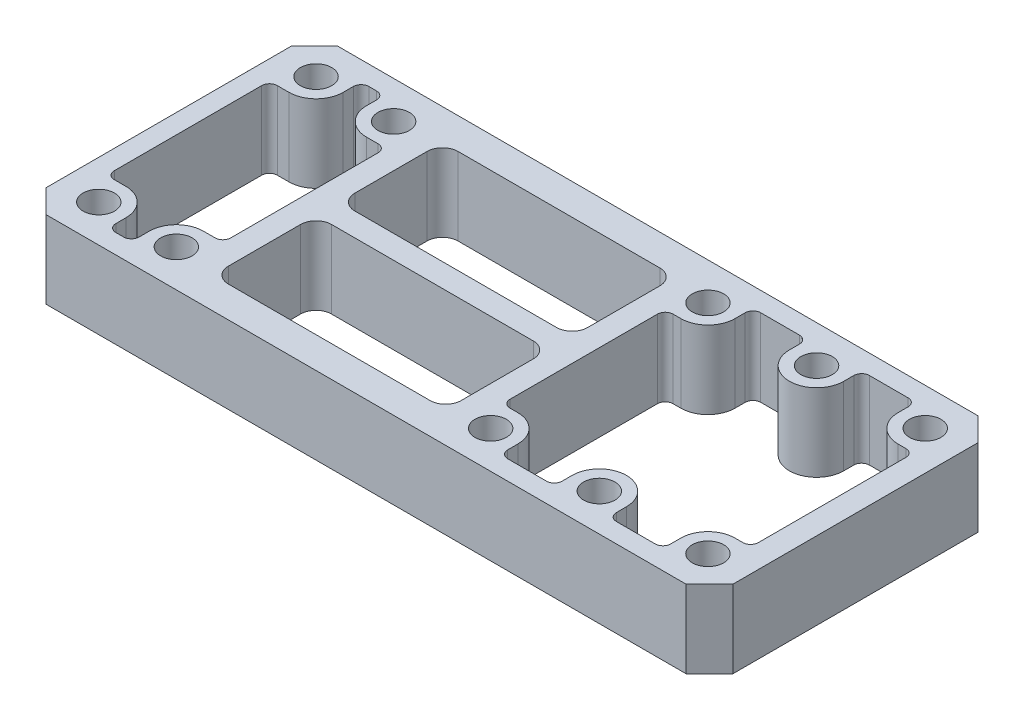
from build123d import *

# Parameters (mm, degrees)
SKETCH_1_W          = 88.5
SKETCH_1_H          = 37.6
SKETCH_1_R          = 2.025
EXTRUDE_1_DEPTH     = 10
CUT_EXTRUDE_1_DEPTH = 11
CUT_EXTRUDE_2_DEPTH = 11
SKETCH_4_W          = 30
SKETCH_4_H          = 29.6
CUT_EXTRUDE_3_DEPTH = 11
SKETCH_5_W          = 30
SKETCH_5_H          = 3
EXTRUDE_2_DEPTH     = 10
FILLET_1_R          = 2
CHAMFER_1_SIZE      = 3


with BuildPart() as part:
    # 草图1 → 凸台-拉伸1 (new body)
    with BuildSketch(Plane(origin=(0, 0, 0), x_dir=(1, 0, 0), z_dir=(0, 1, 0))):
        with Locations((34.25, 0)):
            Rectangle(SKETCH_1_W, SKETCH_1_H)
        with Locations((-5, 14)):
            Circle(SKETCH_1_R, mode=Mode.SUBTRACT)
        with Locations((5, 14)):
            Circle(SKETCH_1_R, mode=Mode.SUBTRACT)
        with Locations((5, -14)):
            Circle(SKETCH_1_R, mode=Mode.SUBTRACT)
        with Locations((-5, -14)):
            Circle(SKETCH_1_R, mode=Mode.SUBTRACT)
        with Locations((45.5, 14)):
            Circle(SKETCH_1_R, mode=Mode.SUBTRACT)
        with Locations((59.5, 14)):
            Circle(SKETCH_1_R, mode=Mode.SUBTRACT)
        with Locations((73.5, 14)):
            Circle(SKETCH_1_R, mode=Mode.SUBTRACT)
        with Locations((73.5, -14)):
            Circle(SKETCH_1_R, mode=Mode.SUBTRACT)
        with Locations((59.5, -14)):
            Circle(SKETCH_1_R, mode=Mode.SUBTRACT)
        with Locations((45.5, -14)):
            Circle(SKETCH_1_R, mode=Mode.SUBTRACT)
    extrude(amount=EXTRUDE_1_DEPTH)

    # 草图2 → 切除-拉伸1 (cut, through all)
    with BuildSketch(Plane(origin=(0, 10, 0), x_dir=(1, 0, 0), z_dir=(0, 1, 0))):
        with BuildLine():
            Line((-7.5, -9.5), (-7.5, 9.5))
            ThreePointArc((-7.5, 9.5), (-7.207106781, 10.207106781), (-6.5, 10.5))
            Line((-6.5, 10.5), (-5, 10.5))
            ThreePointArc((-5, 10.5), (-2.525126266, 11.525126266), (-1.5, 14))
            Line((-1.5, 14), (-1.5, 15.3))
            ThreePointArc((-1.5, 15.3), (-1.207106781, 16.007106781), (-0.5, 16.3))
            Line((-0.5, 16.3), (0.5, 16.3))
            ThreePointArc((0.5, 16.3), (1.207106781, 16.007106781), (1.5, 15.3))
            Line((1.5, 15.3), (1.5, 14))
            ThreePointArc((1.5, 14), (2.525126266, 11.525126266), (5, 10.5))
            Line((5, 10.5), (6.5, 10.5))
            ThreePointArc((6.5, 10.5), (7.207106781, 10.207106781), (7.5, 9.5))
            Line((7.5, 9.5), (7.5, -9.5))
            ThreePointArc((7.5, -9.5), (7.207106781, -10.207106781), (6.5, -10.5))
            Line((6.5, -10.5), (5, -10.5))
            ThreePointArc((5, -10.5), (2.525126266, -11.525126266), (1.5, -14))
            Line((1.5, -14), (1.5, -15.3))
            ThreePointArc((1.5, -15.3), (1.207106781, -16.007106781), (0.5, -16.3))
            Line((0.5, -16.3), (-0.5, -16.3))
            ThreePointArc((-0.5, -16.3), (-1.207106781, -16.007106781), (-1.5, -15.3))
            Line((-1.5, -15.3), (-1.5, -14))
            ThreePointArc((-1.5, -14), (-2.525126266, -11.525126266), (-5, -10.5))
            Line((-5, -10.5), (-6.5, -10.5))
            ThreePointArc((-6.5, -10.5), (-7.207106781, -10.207106781), (-7.5, -9.5))
        make_face()
    extrude(amount=-CUT_EXTRUDE_1_DEPTH, mode=Mode.SUBTRACT)

    # 草图3 → 切除-拉伸2 (cut, through all)
    with BuildSketch(Plane.XZ):
        with BuildLine():
            Line((43.5, -9.5), (43.5, 9.5))
            ThreePointArc((43.5, 9.5), (43.792893219, 10.207106781), (44.5, 10.5))
            Line((44.5, 10.5), (45.5, 10.5))
            ThreePointArc((45.5, 10.5), (47.974873734, 11.525126266), (49, 14))
            Line((49, 14), (49, 15.3))
            ThreePointArc((49, 15.3), (49.292893219, 16.007106781), (50, 16.3))
            Line((50, 16.3), (55, 16.3))
            ThreePointArc((55, 16.3), (55.707106781, 16.007106781), (56, 15.3))
            Line((56, 15.3), (56, 14))
            ThreePointArc((56, 14), (59.5, 10.5), (63, 14))
            Line((63, 14), (63, 15.3))
            ThreePointArc((63, 15.3), (63.292893219, 16.007106781), (64, 16.3))
            Line((64, 16.3), (69, 16.3))
            ThreePointArc((69, 16.3), (69.707106781, 16.007106781), (70, 15.3))
            Line((70, 15.3), (70, 14))
            ThreePointArc((70, 14), (71.025126266, 11.525126266), (73.5, 10.5))
            Line((73.5, 10.5), (74.5, 10.5))
            ThreePointArc((74.5, 10.5), (75.207106781, 10.207106781), (75.5, 9.5))
            Line((75.5, 9.5), (75.5, -9.5))
            ThreePointArc((75.5, -9.5), (75.207106781, -10.207106781), (74.5, -10.5))
            Line((74.5, -10.5), (73.5, -10.5))
            ThreePointArc((73.5, -10.5), (71.025126266, -11.525126266), (70, -14))
            Line((70, -14), (70, -15.3))
            ThreePointArc((70, -15.3), (69.707106781, -16.007106781), (69, -16.3))
            Line((69, -16.3), (64, -16.3))
            ThreePointArc((64, -16.3), (63.292893219, -16.007106781), (63, -15.3))
            Line((63, -15.3), (63, -14))
            ThreePointArc((63, -14), (59.5, -10.5), (56, -14))
            Line((56, -14), (56, -15.3))
            ThreePointArc((56, -15.3), (55.707106781, -16.007106781), (55, -16.3))
            Line((55, -16.3), (50, -16.3))
            ThreePointArc((50, -16.3), (49.292893219, -16.007106781), (49, -15.3))
            Line((49, -15.3), (49, -14))
            ThreePointArc((49, -14), (47.974873734, -11.525126266), (45.5, -10.5))
            Line((45.5, -10.5), (44.5, -10.5))
            ThreePointArc((44.5, -10.5), (43.792893219, -10.207106781), (43.5, -9.5))
        make_face()
    extrude(amount=-CUT_EXTRUDE_2_DEPTH, mode=Mode.SUBTRACT)

    # 草图4 → 切除-拉伸3 (cut, through all)
    with BuildSketch(Plane.XZ):
        with Locations((25.5, 0)):
            Rectangle(SKETCH_4_W, SKETCH_4_H)
    extrude(amount=-CUT_EXTRUDE_3_DEPTH, mode=Mode.SUBTRACT)

    # 草图5 → 凸台-拉伸2 (add)
    with BuildSketch(Plane.XZ):
        with Locations((25.5, 0)):
            Rectangle(SKETCH_5_W, SKETCH_5_H)
    extrude(amount=-EXTRUDE_2_DEPTH)

    # 圆角1
    fillet_1_edges = [part.edges().sort_by_distance(p)[0] for p in [
        (40.5, 5, 14.8),
        (40.5, 5, -14.8),
        (10.5, 5, -14.8),
        (10.5, 5, 14.8),
        (40.5, 5, -1.5),
        (40.5, 5, 1.5),
        (10.5, 5, 1.5),
        (10.5, 5, -1.5),
    ]]
    fillet(fillet_1_edges, radius=FILLET_1_R)

    # 倒角1
    chamfer_1_edges = [part.edges().sort_by_distance(p)[0] for p in [
        (-10, 5, -18.8),
        (78.5, 5, -18.8),
        (78.5, 5, 18.8),
        (-10, 5, 18.8),
    ]]
    chamfer(chamfer_1_edges, length=CHAMFER_1_SIZE)


solid = part.part
